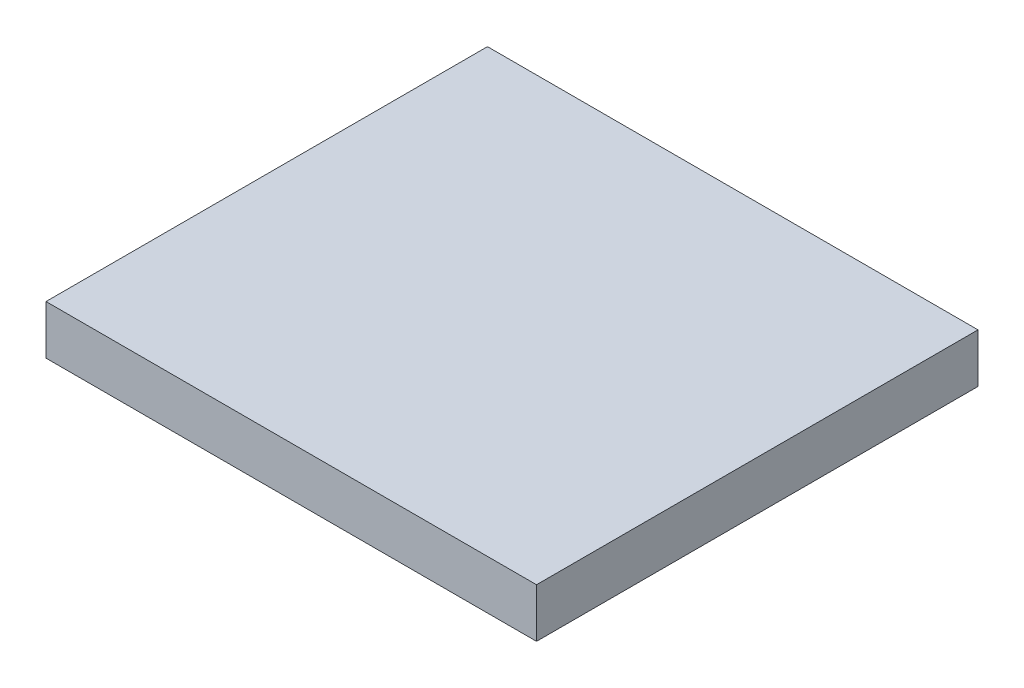
from build123d import *

# Parameters (mm, degrees)
SKETCH1_W           = 508
SKETCH1_H           = 457.2
BOSS_EXTRUDE1_DEPTH = 50.8


with BuildPart() as part:
    # Sketch1 → Boss-Extrude1 (new body)
    with BuildSketch(Plane(origin=(0, 0, 0), x_dir=(1, 0, 0), z_dir=(0, 1, 0))):
        Rectangle(SKETCH1_W, SKETCH1_H)
    extrude(amount=BOSS_EXTRUDE1_DEPTH)


solid = part.part
